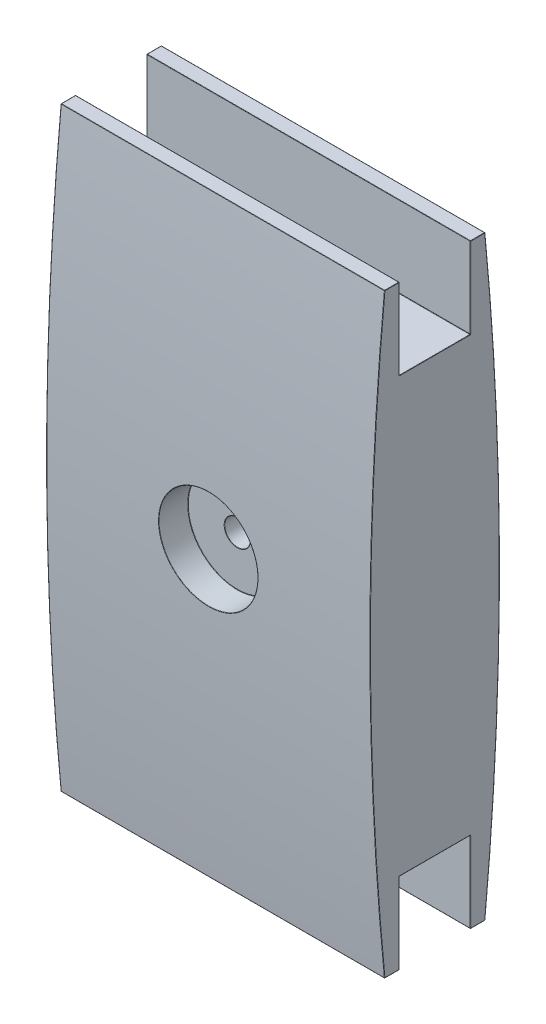
from build123d import *

# Parameters (mm, degrees)
BOSS_EXTRUDE1_DEPTH     = 100
SKETCH4_R               = 15.278631479
CUT_EXTRUDE1_DEPTH      = 9
SKETCH5_R               = 4
CUT_EXTRUDE2_DEPTH      = 1.000000103
CUT_EXTRUDE2_DEPTH_BACK = 41.000000103
FILLET1_R               = 0.1


with BuildPart() as part:
    # Sketch2 → Boss-Extrude1 (new body)
    with BuildSketch(Plane(origin=(0, 0, 0), x_dir=(0, 0, -1), z_dir=(1, 0, 0))):
        with BuildLine():
            Line((-11, 92), (-11, 67))
            Line((-11, 67), (11, 67))
            Line((11, 67), (11, 92))
            Line((11, 92), (15.5, 92))
            ThreePointArc((15.5, 92), (20, 0), (15.5, -92))
            Line((15.5, -92), (11, -92))
            Line((11, -92), (11, -67))
            Line((11, -67), (-11, -67))
            Line((-11, -67), (-11, -92))
            Line((-11, -92), (-15.5, -92))
            ThreePointArc((-15.5, -92), (-20, 0), (-15.5, 92))
            Line((-15.5, 92), (-11, 92))
        make_face()
    extrude(amount=BOSS_EXTRUDE1_DEPTH)

    # Sketch4 → Cut-Extrude1 (cut)
    with BuildSketch(Plane.XY.offset(20)):
        with Locations((50, 0)):
            Circle(SKETCH4_R)
    cut_extrude1 = extrude(amount=-CUT_EXTRUDE1_DEPTH, mode=Mode.SUBTRACT)

    # Mirror1: Cut-Extrude1 across plane
    add(cut_extrude1.mirror(Plane.XY), mode=Mode.SUBTRACT)

    # Sketch5 → Cut-Extrude2 (cut, two sides)
    with BuildSketch(Plane.XY.offset(20)) as cut_extrude2_sk:
        with Locations((50, 0)):
            Circle(SKETCH5_R)
    extrude(amount=CUT_EXTRUDE2_DEPTH, mode=Mode.SUBTRACT)
    extrude(cut_extrude2_sk.sketch, amount=-CUT_EXTRUDE2_DEPTH_BACK, mode=Mode.SUBTRACT)

    # Fillet1
    fillet1_edges = [part.edges().sort_by_distance(p)[0] for p in [
        (0, 92, -13.25),
        (0, 0, -20),
        (100, 79.5, 11),
        (0, -92, -13.25),
        (0, -79.5, -11),
        (0, -67, 0),
        (0, -79.5, 11),
        (0, -92, 13.25),
        (0, 0, 20),
        (0, 92, 13.25),
        (0, 79.5, 11),
        (0, 67, 0),
        (0, 79.5, -11),
        (100, 92, 13.25),
        (50, 92, -11),
        (50, 92, -15.5),
        (50, -92, -15.5),
        (100, 0, 20),
        (50, -92, -11),
        (50, -67, -11),
        (50, -67, 11),
        (50, -92, 11),
        (50, -92, 15.5),
        (50, 92, 15.5),
        (50, 92, 11),
        (50, 67, 11),
        (50, 67, -11),
        (100, -92, 13.25),
        (100, -79.5, 11),
        (100, -67, 0),
        (34.721368518, 5.4e-08, 20.000000003),
        (100, -79.5, -11),
        (34.721368521, 0, 11),
        (100, -92, -13.25),
        (34.721368518, 4e-09, -20.000000003),
        (100, 0, -20),
        (34.721368521, 0, -11),
        (100, 92, -13.25),
        (100, 79.5, -11),
        (46, 0, 11),
        (46, 0, -11),
        (100, 67, 0),
    ]]
    fillet(fillet1_edges, radius=FILLET1_R)


solid = part.part
